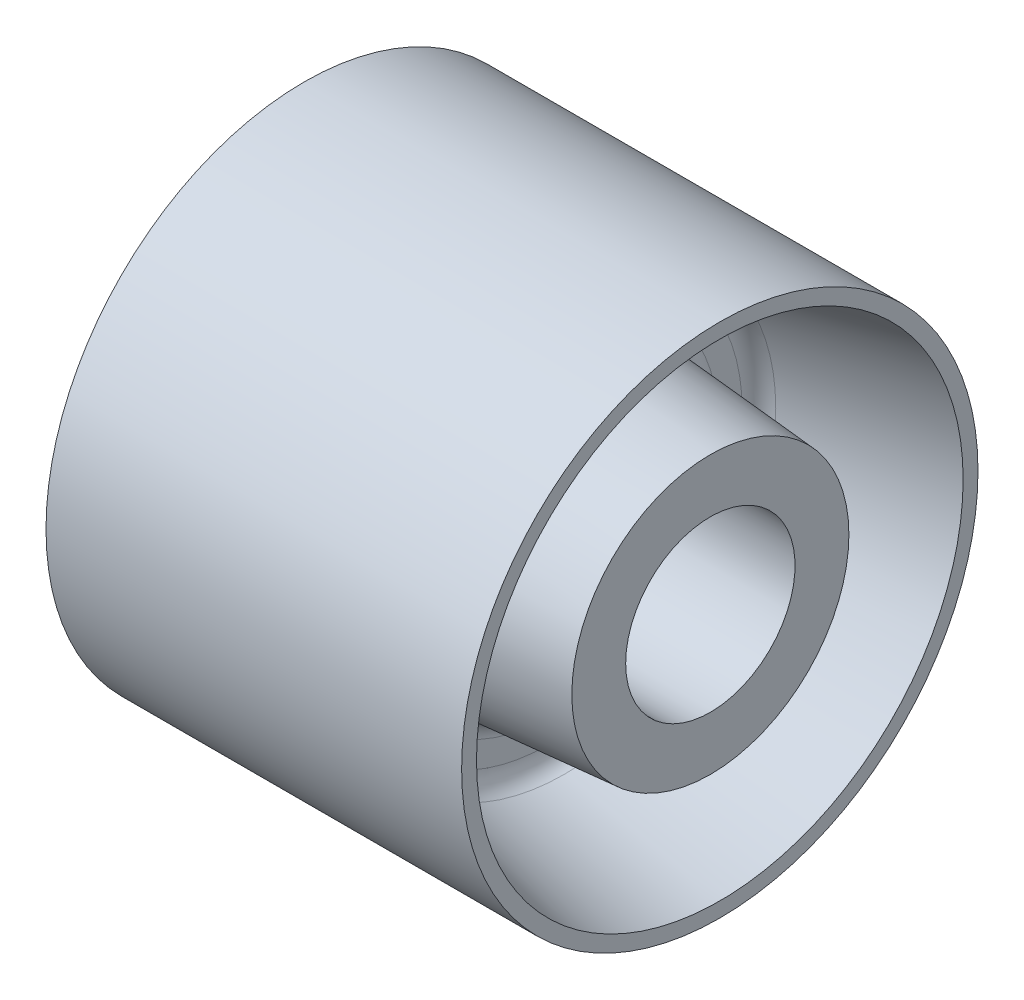
from build123d import *

# Parameters (mm, degrees)
FILLET4_R = 3
FILLET5_R = 3


with BuildPart() as part:
    # Sketch1 → Revolve1 (revolve)
    with BuildSketch(Plane.XY):
        Polygon((0, 13.45), (0, 41), (33, 41), (33, 38.639986999), (6, 33), (6, 24), (31.5, 22), (31.5, 13.45), align=None)
    revolve(axis=Axis((-113.627257408, 0, 0), (1, 0, 0)))

    # Fillet4
    fillet4_edges = [part.edges().sort_by_distance(p)[0] for p in [
        (6, -33, 0),
    ]]
    fillet(fillet4_edges, radius=FILLET4_R)

    # Fillet5
    fillet5_edges = [part.edges().sort_by_distance(p)[0] for p in [
        (6, -24, 0),
    ]]
    fillet(fillet5_edges, radius=FILLET5_R)

    # Mirror1: part across plane


with BuildPart() as part_1:
    add(part.part)
    add(part.part.mirror(Plane(origin=(0, 0, 0), x_dir=(0, 0, 1), z_dir=(1, 0, 0))))


solid = part_1.part
